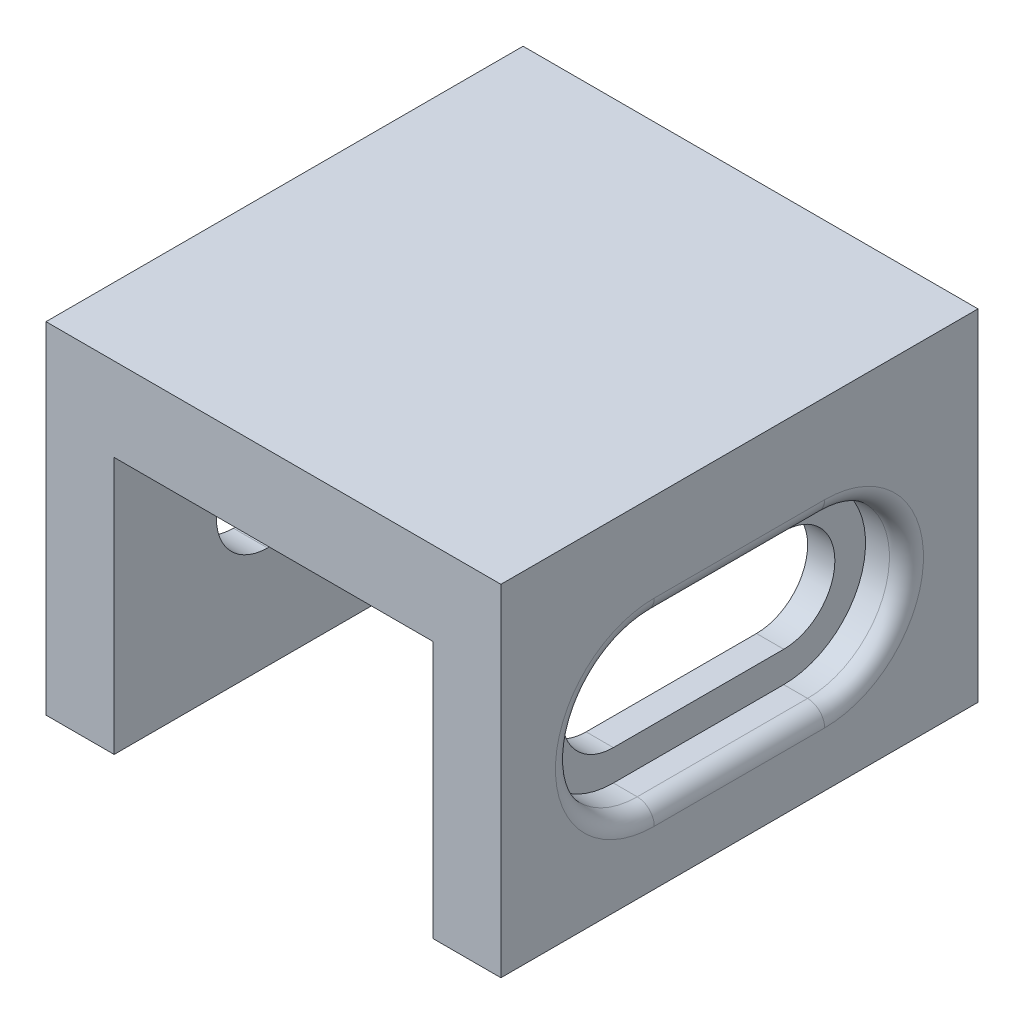
from build123d import *

# Parameters (mm, degrees)
SKETCH1_W           = 26.7
SKETCH1_H           = 28
BOSS_EXTRUDE1_DEPTH = 20
CUT_EXTRUDE1_DEPTH  = 27.5
CUT_EXTRUDE2_DEPTH  = 2
CUT_EXTRUDE3_DEPTH  = 2.4
SKETCH5_W           = 18.7
SKETCH5_H           = 28
CUT_EXTRUDE4_DEPTH  = 15.1
FILLET1_R           = 1


with BuildPart() as part:
    # Sketch1 → Boss-Extrude1 (new body)
    with BuildSketch(Plane(origin=(0, 0, 0), x_dir=(1, 0, 0), z_dir=(0, 1, 0))):
        with Locations((13.35, 14)):
            Rectangle(SKETCH1_W, SKETCH1_H)
    extrude(amount=BOSS_EXTRUDE1_DEPTH)

    # Sketch2 → Cut-Extrude1 (cut)
    with BuildSketch(Plane.ZY):
        with BuildLine():
            Line((-19, 12), (-9, 12))
            ThreePointArc((-9, 12), (-6, 9), (-9, 6))
            Line((-9, 6), (-19, 6))
            ThreePointArc((-19, 6), (-22, 9), (-19, 12))
        make_face()
    extrude(amount=-CUT_EXTRUDE1_DEPTH, mode=Mode.SUBTRACT)

    # Sketch3 → Cut-Extrude2 (cut)
    with BuildSketch(Plane.ZY):
        with BuildLine():
            Line((-19, 13.8), (-9, 13.8))
            ThreePointArc((-9, 13.8), (-4.2, 9), (-9, 4.2))
            Line((-9, 4.2), (-19, 4.2))
            ThreePointArc((-19, 4.2), (-23.8, 9), (-19, 13.8))
        make_face()
    extrude(amount=-CUT_EXTRUDE2_DEPTH, mode=Mode.SUBTRACT)

    # Sketch4 → Cut-Extrude3 (cut)
    with BuildSketch(Plane(origin=(26.7, 0, 0), x_dir=(0, 0, -1), z_dir=(1, 0, 0))):
        with BuildLine():
            Line((9, 13.8), (19, 13.8))
            ThreePointArc((19, 13.8), (23.8, 9), (19, 4.2))
            Line((19, 4.2), (9, 4.2))
            ThreePointArc((9, 4.2), (4.2, 9), (9, 13.8))
        make_face()
    extrude(amount=-CUT_EXTRUDE3_DEPTH, mode=Mode.SUBTRACT)

    # Sketch5 → Cut-Extrude4 (cut)
    with BuildSketch(Plane(origin=(0, 0, 0), x_dir=(1, 0, 0), z_dir=(0, 1, 0))):
        with Locations((13.35, 14)):
            Rectangle(SKETCH5_W, SKETCH5_H)
    extrude(amount=CUT_EXTRUDE4_DEPTH, mode=Mode.SUBTRACT)

    # Fillet1
    fillet1_edges = [part.edges().sort_by_distance(p)[0] for p in [
        (0, 9, -23.8),
        (0, 4.2, -14),
        (0, 9, -4.2),
        (0, 13.8, -14),
        (26.7, 9, -4.2),
        (26.7, 4.2, -14),
        (26.7, 9, -23.8),
        (26.7, 13.8, -14),
    ]]
    fillet(fillet1_edges, radius=FILLET1_R)


solid = part.part
